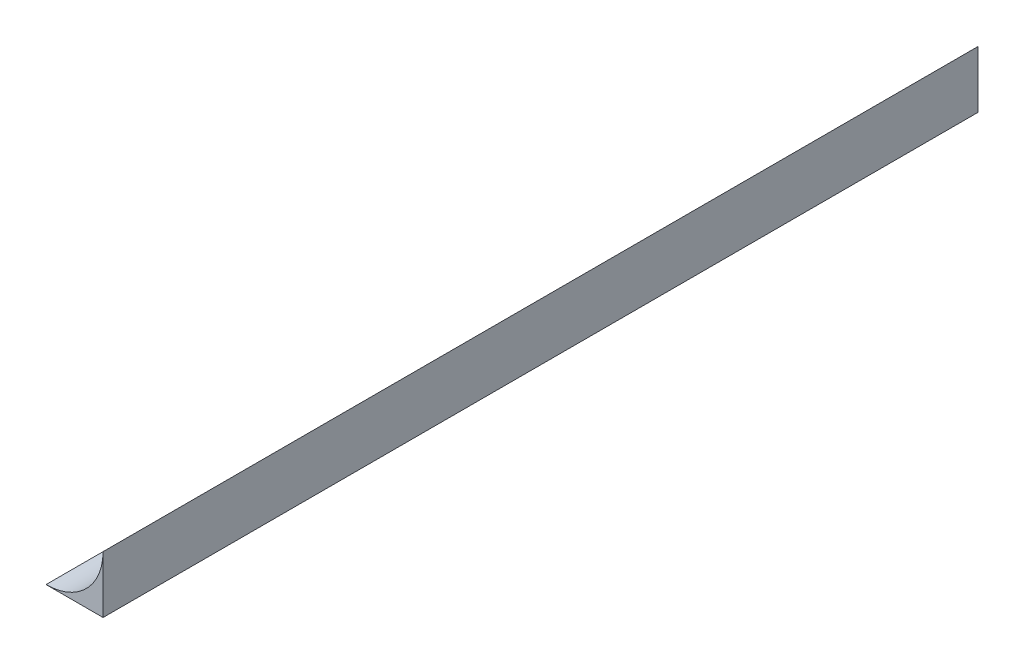
from build123d import *

# Parameters (mm, degrees)
SKETCH1_W                  = 5
SKETCH1_H                  = 110
BOSS_EXTRUDE1_DEPTH        = 120
BOSS_EXTRUDE1_DEPTH_BACK   = 110
BOSS_EXTRUDE1_2_DEPTH      = 120
BOSS_EXTRUDE1_2_DEPTH_BACK = 110
SKETCH2_W                  = 5
SKETCH2_H                  = 37
BOSS_EXTRUDE2_DEPTH        = 50
SKETCH3_W                  = 220
SKETCH3_H                  = 5
BOSS_EXTRUDE3_DEPTH        = 50
SKETCH4_W                  = 230
SKETCH4_H                  = 73
BOSS_EXTRUDE6_DEPTH        = 5
FILLET3_R                  = 15
CUT_EXTRUDE3_DEPTH         = 231
SKETCH5_W                  = 348
SKETCH5_H                  = 227
SKETCH5_W_2                = 328
SKETCH5_H_2                = 207
BOSS_EXTRUDE7_DEPTH        = 5
BOSS_EXTRUDE8_DEPTH        = 59
FILLET5_R                  = 15
BOSS_EXTRUDE9_DEPTH        = 5
BOSS_EXTRUDE10_DEPTH       = 5
FILLET6_R                  = 3
CUT_EXTRUDE4_DEPTH         = 60
CUT_EXTRUDE4_DEPTH_BACK    = 290
SKETCH15_R                 = 1.2
CUT_EXTRUDE5_DEPTH         = 16
SKETCH18_R                 = 3
CUT_EXTRUDE6_DEPTH         = 9


with BuildPart() as part:
    # Sketch1 → Boss-Extrude1 (new body, two sides)
    with BuildSketch(Plane(origin=(0, 0, 0), x_dir=(0, 0, -1), z_dir=(1, 0, 0))) as boss_extrude1_sk:
        with Locations((-112.5, 55)):
            Rectangle(SKETCH1_W, SKETCH1_H)
    extrude(amount=BOSS_EXTRUDE1_DEPTH)
    extrude(boss_extrude1_sk.sketch, amount=-BOSS_EXTRUDE1_DEPTH_BACK)



with BuildPart() as body_2:
    # Sketch1 → Boss-Extrude1 2 (new body, two sides)
    with BuildSketch(Plane(origin=(0, 0, 0), x_dir=(0, 0, -1), z_dir=(1, 0, 0))) as boss_extrude1_2_sk:
        with Locations((112.5, 55)):
            Rectangle(SKETCH1_W, SKETCH1_H)
    extrude(amount=BOSS_EXTRUDE1_2_DEPTH)
    extrude(boss_extrude1_2_sk.sketch, amount=-BOSS_EXTRUDE1_2_DEPTH_BACK)


with BuildPart() as part_1:
    add(part.part)

    add(body_2.part)  # Boss-Extrude2 merges body 2
    # Sketch2 → Boss-Extrude2 (add)
    with BuildSketch(Plane.ZY.offset(110)):
        with Locations((-112.5, 18.5)):
            Rectangle(SKETCH2_W, SKETCH2_H)
        with Locations((112.5, 18.5)):
            Rectangle(SKETCH2_W, SKETCH2_H)
    extrude(amount=BOSS_EXTRUDE2_DEPTH)

    # Sketch3 → Boss-Extrude3 (add)
    with BuildSketch(Plane.ZY.offset(160)):
        with Locations((0, 34.5)):
            Rectangle(SKETCH3_W, SKETCH3_H)
    extrude(amount=-BOSS_EXTRUDE3_DEPTH)

    # Sketch4 → Boss-Extrude6 (add)
    with BuildSketch(Plane.ZY.offset(110)):
        with Locations((0, 73.5)):
            Rectangle(SKETCH4_W, SKETCH4_H)
    extrude(amount=BOSS_EXTRUDE6_DEPTH)

    # Fillet3
    fillet3_edges = [part_1.edges().sort_by_distance(p)[0] for p in [
        (-115, 37, 0),
    ]]
    fillet(fillet3_edges, radius=FILLET3_R)

    # Sketch9 → Cut-Extrude3 (cut, through all)
    with BuildSketch(Plane.XY.offset(115)):
        Polygon((120, 110), (116.464466094, 106.464466094), (120, 102.928932188), align=None)
    extrude(amount=-CUT_EXTRUDE3_DEPTH, mode=Mode.SUBTRACT)

    # Sketch10 → Boss-Extrude8 (add)
    with BuildSketch(Plane.XY.offset(115)):
        Polygon((120, 110), (111.464466094, 110), (111.464466094, 0), (120, 0), (120, 102.928932188), (116.464466094, 106.464466094), align=None)
    boss_extrude8 = extrude(amount=BOSS_EXTRUDE8_DEPTH)

    # Mirror3: Boss-Extrude8 across plane
    add(boss_extrude8.mirror(Plane.XY))

    # Fillet5
    fillet5_edges = [part_1.edges().sort_by_distance(p)[0] for p in [
        (111.464466094, 55, 115),
        (111.464466094, 55, -115),
    ]]
    fillet(fillet5_edges, radius=FILLET5_R)

    # Fillet6
    fillet6_edges = [part_1.edges().sort_by_distance(p)[0] for p in [
        (111.464466094, 55, 174),
        (111.464466094, 55, -174),
    ]]
    fillet(fillet6_edges, radius=FILLET6_R)


with BuildPart() as body_2_2:
    # Sketch5 → Boss-Extrude7 (new body)
    with BuildSketch(Plane(origin=(115, 115, 0), x_dir=(0, 0, 1), z_dir=(-0.707106781, -0.707106781, 0))):
        with Locations((0, -120.571067812)):
            Rectangle(SKETCH5_W, SKETCH5_H)
        with Locations((0, -120.571067812)):
            Rectangle(SKETCH5_W_2, SKETCH5_H_2, mode=Mode.SUBTRACT)
    extrude(amount=BOSS_EXTRUDE7_DEPTH)


with BuildPart() as body_3:
    # Sketch12 → Boss-Extrude9 (new body)
    with BuildSketch(Plane.XY.offset(174)):
        Polygon((120, 0), (222.928932188, 0), (120, 102.928932188), align=None)
    extrude(amount=-BOSS_EXTRUDE9_DEPTH)


with BuildPart() as body_4:
    # Sketch13 → Boss-Extrude10 (new body)
    with BuildSketch(Plane(origin=(0, 0, -174), x_dir=(-1, 0, 0), z_dir=(0, 0, -1))):
        Polygon((-120, 102.928932188), (-120, 0), (-222.928932188, 0), align=None)
    extrude(amount=-BOSS_EXTRUDE10_DEPTH)


with BuildPart() as cut_extrude4_tool:
    # Sketch14 → Cut-Extrude4 (new body, two sides)
    with BuildSketch(Plane.XY.offset(115)) as cut_extrude4_sk:
        Polygon((-130, 37), (-115, 37), (-115, 120.163626998), (321.994934014, 120.163626998), (321.994934014, -84.01084078), (-160, -84.01084078), (-160, 37), align=None)
    extrude(amount=CUT_EXTRUDE4_DEPTH)
    extrude(cut_extrude4_sk.sketch, amount=-CUT_EXTRUDE4_DEPTH_BACK)


with BuildPart() as part_2:
    add(part_1.part)

    # Cut-Extrude4: cut by cut_extrude4_tool
    add(cut_extrude4_tool.part, mode=Mode.SUBTRACT)

    # Sketch15 → Cut-Extrude5 (cut, through all)
    with BuildSketch(Plane.XZ.offset(-37)):
        with Locations((-121, -70)):
            Circle(SKETCH15_R)
        with Locations((-121, 70)):
            Circle(SKETCH15_R)
    extrude(amount=-CUT_EXTRUDE5_DEPTH, mode=Mode.SUBTRACT)

    # Sketch18 → Cut-Extrude6 (cut)
    with BuildSketch(Plane(origin=(0, 47, 0), x_dir=(-1, 0, 0), z_dir=(0, -1, 0))):
        with Locations((121, 70)):
            Circle(SKETCH18_R)
        with Locations((121, -70)):
            Circle(SKETCH18_R)
    extrude(amount=CUT_EXTRUDE6_DEPTH, mode=Mode.SUBTRACT)


with BuildPart() as body_2_2_1:
    add(body_2_2.part)

    # Cut-Extrude4: cut by cut_extrude4_tool
    add(cut_extrude4_tool.part, mode=Mode.SUBTRACT)


with BuildPart() as body_3_1:
    add(body_3.part)

    # Cut-Extrude4: cut by cut_extrude4_tool
    add(cut_extrude4_tool.part, mode=Mode.SUBTRACT)


with BuildPart() as body_4_1:
    add(body_4.part)

    # Cut-Extrude4: cut by cut_extrude4_tool
    add(cut_extrude4_tool.part, mode=Mode.SUBTRACT)


solid = part_2.part
